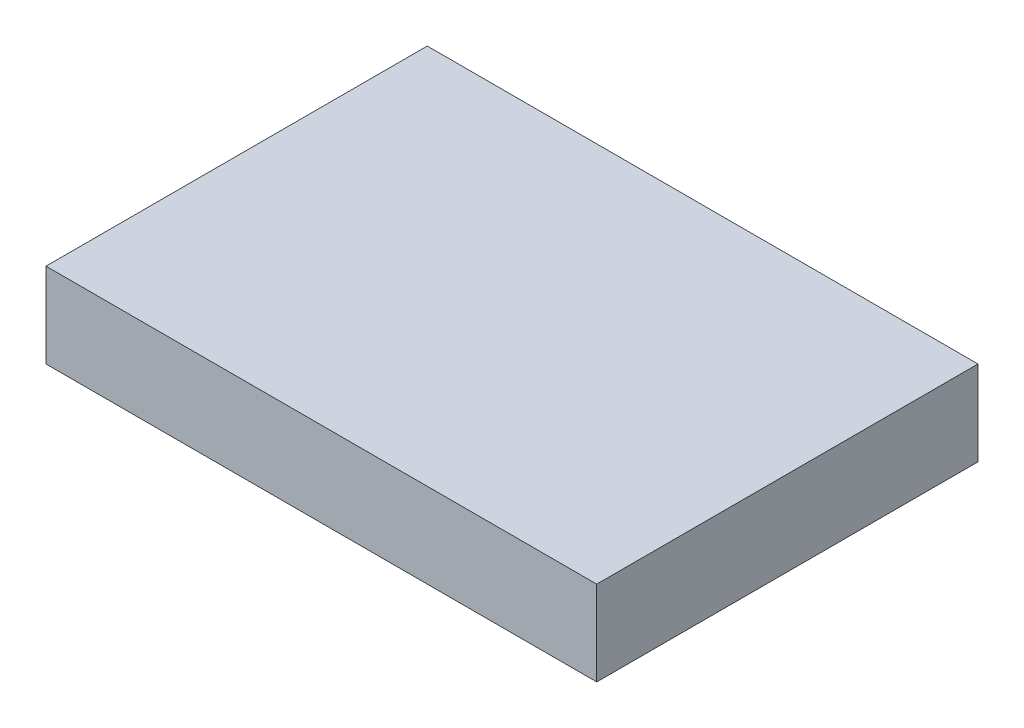
from build123d import *

# Parameters (mm, degrees)
SKETCH1_W           = 65
SKETCH1_H           = 45
BOSS_EXTRUDE1_DEPTH = 10


with BuildPart() as part:
    # Sketch1 → Boss-Extrude1 (new body)
    with BuildSketch(Plane(origin=(0, 0, 0), x_dir=(1, 0, 0), z_dir=(0, 1, 0))):
        with Locations((32.5, -22.5)):
            Rectangle(SKETCH1_W, SKETCH1_H)
    extrude(amount=BOSS_EXTRUDE1_DEPTH)


solid = part.part
